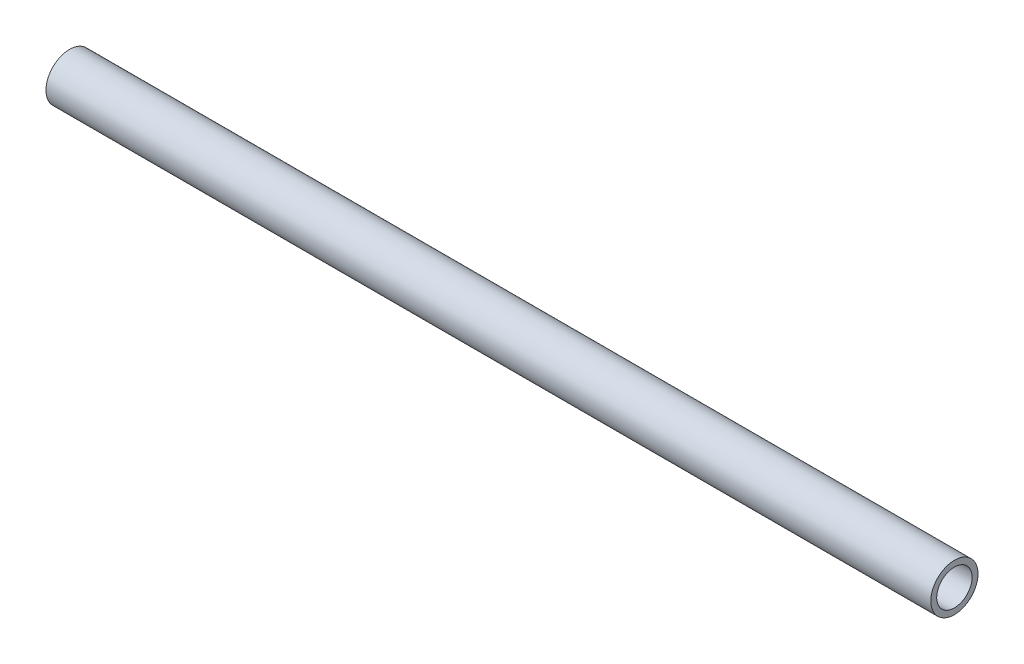
from build123d import *

# Parameters (mm, degrees)
SCHIZZO2_R                = 8
SCHIZZO2_R_2              = 6
ESTRUSIONE_SOTTILE1_DEPTH = 150


with BuildPart() as part:
    # Schizzo2 → Estrusione-Sottile1 (new, symmetric)
    with BuildSketch(Plane(origin=(0, 0, 0), x_dir=(0, 0, -1), z_dir=(1, 0, 0))):
        Circle(SCHIZZO2_R)
        Circle(SCHIZZO2_R_2, mode=Mode.SUBTRACT)
    extrude(amount=ESTRUSIONE_SOTTILE1_DEPTH, both=True)


solid = part.part
